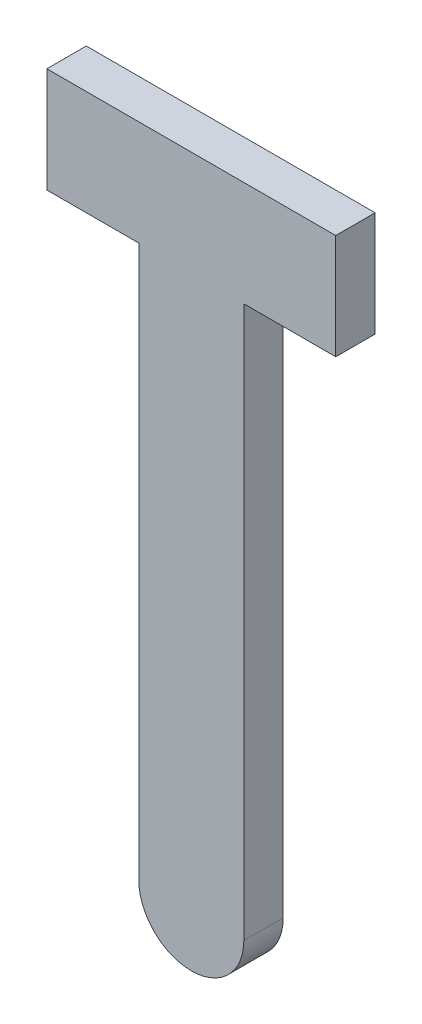
from build123d import *

# Parameters (mm, degrees)
EXTRUSION1_DEPTH = 1.5


with BuildPart() as part:
    # Esquisse1 → Extrusion1 (new body)
    with BuildSketch(Plane.XY):
        with BuildLine():
            Line((-5.5, 0), (5.5, 0))
            Line((5.5, 0), (5.5, -4))
            Line((5.5, -4), (2, -4))
            Line((2, -4), (2, -25))
            ThreePointArc((2, -25), (0, -27), (-2, -25))
            Line((-2, -25), (-2, -4))
            Line((-2, -4), (-5.5, -4))
            Line((-5.5, -4), (-5.5, 0))
        make_face()
    extrude(amount=EXTRUSION1_DEPTH)


solid = part.part
